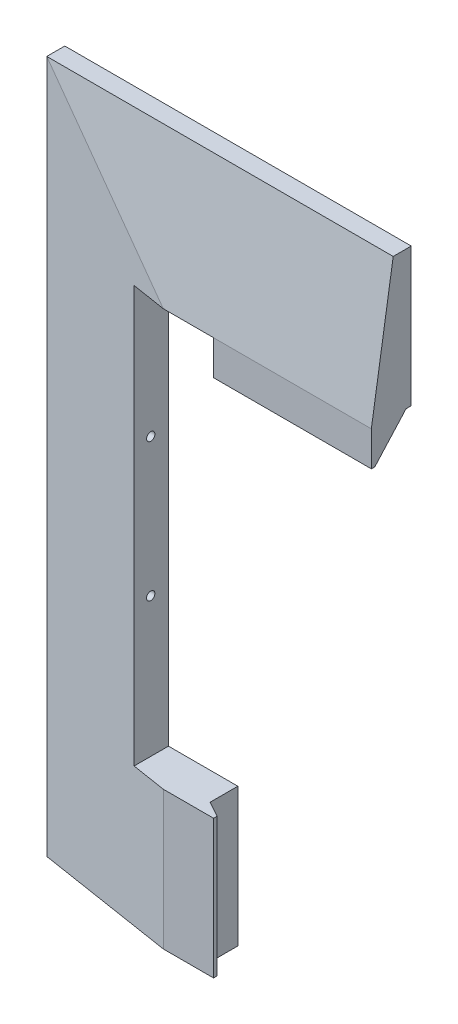
from build123d import *

# Parameters (mm, degrees)
DODANIE_WYCI_GNI_CIE1_DEPTH = 5.2
SZKIC3_W                    = 60
SZKIC3_H                    = 159.9
SZKIC5_W                    = 99.9
SZKIC5_H                    = 199.8
SZKIC6_W                    = 49.271239353
SZKIC6_H                    = 120
WYTNIJ_WYCI_GNI_CIE1_DEPTH  = 78
WYTNIJ_WYCI_GNI_CIE2_DEPTH  = 5.6
SZKIC9_R                    = 2.424871131
SZKIC9_R_2                  = 1.2
DODANIE_WYCI_GNI_CIE3_DEPTH = 3.8
SZKIC10_W                   = 50
SZKIC10_H                   = 39.9
WYTNIJ_WYCI_GNI_CIE4_DEPTH  = 24
DODANIE_WYCI_GNI_CIE4_DEPTH = 39.9
DODANIE_WYCI_GNI_CIE5_DEPTH = 45.5


with BuildPart() as part:
    # Szkic2 → Dodanie-wyciągnięcie1 (new body)
    with BuildSketch(Plane.XY):
        Polygon((18.542832418, 83.245366469), (18.542832418, 43.345366469), (-51.457167582, 43.345366469), (-51.457167582, -76.654633531), (18.542832418, -76.654633531), (18.542832418, -116.554633531), (-81.357167582, -116.554633531), (-81.357167582, 83.245366469), align=None)
    extrude(amount=DODANIE_WYCI_GNI_CIE1_DEPTH)

    # Szkic3 → Wyciągnięcie po profilach3 section 0
    with BuildSketch(Plane.XY.offset(11.5)):
        with Locations((-11.457167582, 3.295366469)):
            Rectangle(SZKIC3_W, SZKIC3_H)
    # Szkic5 → Wyciągnięcie po profilach3 section 1
    with BuildSketch(Plane.XY.offset(5.2)):
        with Locations((-31.407167582, -16.654633531)):
            Rectangle(SZKIC5_W, SZKIC5_H)
    loft()

    # Szkic6 → Wytnij-wyciągnięcie1 (cut)
    with BuildSketch(Plane(origin=(-51.457167582, 0, 0), x_dir=(0, 0, -1), z_dir=(1, 0, 0))):
        with Locations((-24.635619677, -16.654633531)):
            Rectangle(SZKIC6_W, SZKIC6_H)
    extrude(amount=WYTNIJ_WYCI_GNI_CIE1_DEPTH, mode=Mode.SUBTRACT)

    # Szkic7 → Wytnij-wyciągnięcie2 (cut)
    with BuildSketch(Plane(origin=(-51.457167582, 0, 0), x_dir=(0, 0, -1), z_dir=(1, 0, 0))):
        Polygon((-5.12, -34.1297624), (-7.22, -35.342197966), (-7.22, -37.767069096), (-5.12, -38.979504662), (-3.02, -37.767069096), (-3.02, -35.342197966), align=None)
        Polygon((-5.12, 5.6702376), (-7.22, 4.457802034), (-7.22, 2.032930904), (-5.12, 0.820495338), (-3.02, 2.032930904), (-3.02, 4.457802034), align=None)
    extrude(amount=-WYTNIJ_WYCI_GNI_CIE2_DEPTH, mode=Mode.SUBTRACT)

    # Szkic9 → Dodanie-wyciągnięcie3 (add)
    with BuildSketch(Plane(origin=(-51.457167582, 0, 0), x_dir=(0, 0, -1), z_dir=(1, 0, 0))):
        with Locations((-5.12, 3.245366469)):
            Circle(SZKIC9_R)
        with Locations((-5.12, 3.245366469)):
            Circle(SZKIC9_R_2, mode=Mode.SUBTRACT)
        with Locations((-5.12, -36.554633531)):
            Circle(SZKIC9_R)
        with Locations((-5.12, -36.554633531)):
            Circle(SZKIC9_R_2, mode=Mode.SUBTRACT)
    extrude(amount=-DODANIE_WYCI_GNI_CIE3_DEPTH)

    # Szkic10 → Wytnij-wyciągnięcie4 (cut)
    with BuildSketch(Plane.XY.offset(11.5)):
        with Locations((-6.457167582, 63.295366469)):
            Rectangle(SZKIC10_W, SZKIC10_H)
    extrude(amount=-WYTNIJ_WYCI_GNI_CIE4_DEPTH, mode=Mode.SUBTRACT)

    # Szkic12 → Dodanie-wyciągnięcie4 (add)
    with BuildSketch(Plane(origin=(0, 83.245366469, 0), x_dir=(1, 0, 0), z_dir=(0, 1, 0))):
        Polygon((-31.457167582, -11.5), (-26.957167582, -11.5), (-26.957167582, -10.5), (-31.457167582, -8), align=None)
    extrude(amount=-DODANIE_WYCI_GNI_CIE4_DEPTH)

    # Szkic13 → Dodanie-wyciągnięcie5 (add)
    with BuildSketch(Plane(origin=(18.542832418, 0, 0), x_dir=(0, 0, -1), z_dir=(1, 0, 0))):
        Polygon((-11.5, -76.654633531), (-1.5, -76.654633531), (-10.5, -66.654633531), (-11.5, -66.654633531), align=None)
    extrude(amount=-DODANIE_WYCI_GNI_CIE5_DEPTH)


with BuildPart() as body_2:
    # Lustro1: mirrored copy
    add(part.part.mirror(Plane(origin=(-81.357167582, 83.245366469, 5.2), x_dir=(0, 0, 1), z_dir=(0, -1, 0))))


solid = body_2.part
